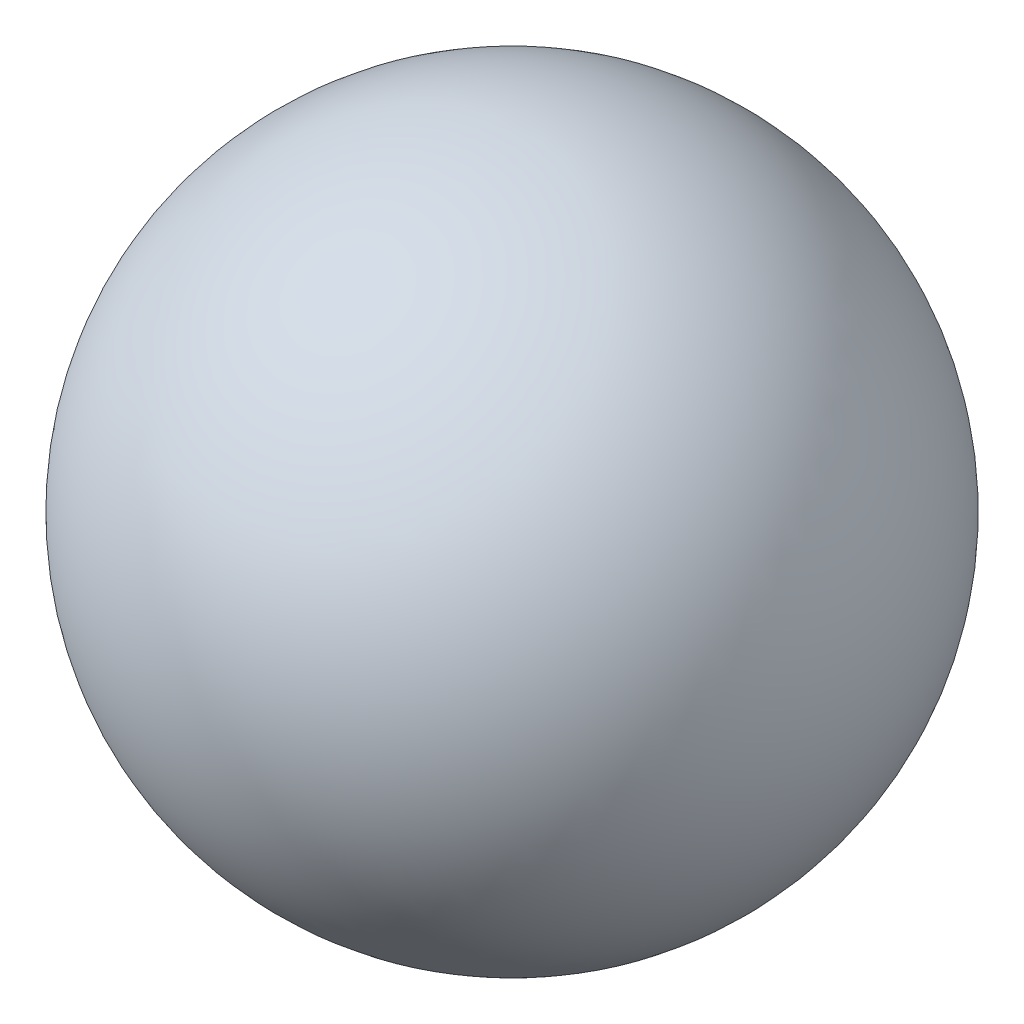
from build123d import *


with BuildPart() as part:
    # Sketch1 → Revolve1 (revolve)
    with BuildSketch(Plane.XY):
        with BuildLine():
            Line((0, 33.5), (0, 28.75))
            Line((0, 28.75), (0, -28.75))
            Line((0, -28.75), (0, -33.5))
            ThreePointArc((0, -33.5), (-33.5, 0), (0, 33.5))
        make_face()
    revolve(axis=Axis((0, 105.084210526, 0), (0, -1, 0)))


solid = part.part
